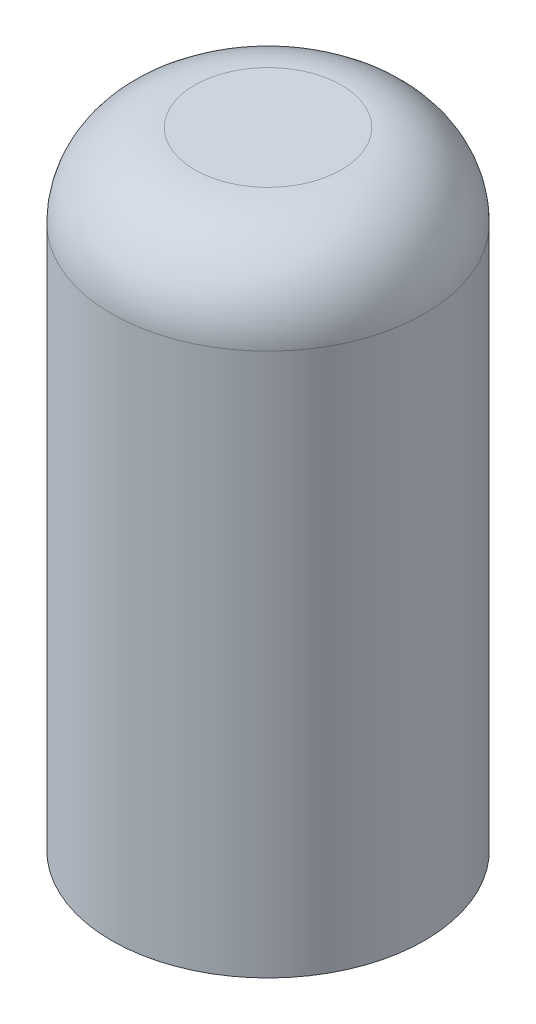
from build123d import *

# Parameters (mm, degrees)
SKETCH1_R           = 56.5
BOSS_EXTRUDE1_DEPTH = 226
FILLET1_R           = 30


with BuildPart() as part:
    # Sketch1 → Boss-Extrude1 (new body)
    with BuildSketch(Plane(origin=(0, 0, 0), x_dir=(1, 0, 0), z_dir=(0, 1, 0))):
        Circle(SKETCH1_R)
    extrude(amount=BOSS_EXTRUDE1_DEPTH)

    # Fillet1
    fillet1_edges = [part.edges().sort_by_distance(p)[0] for p in [
        (-56.5, 226, 0),
    ]]
    fillet(fillet1_edges, radius=FILLET1_R)


solid = part.part
